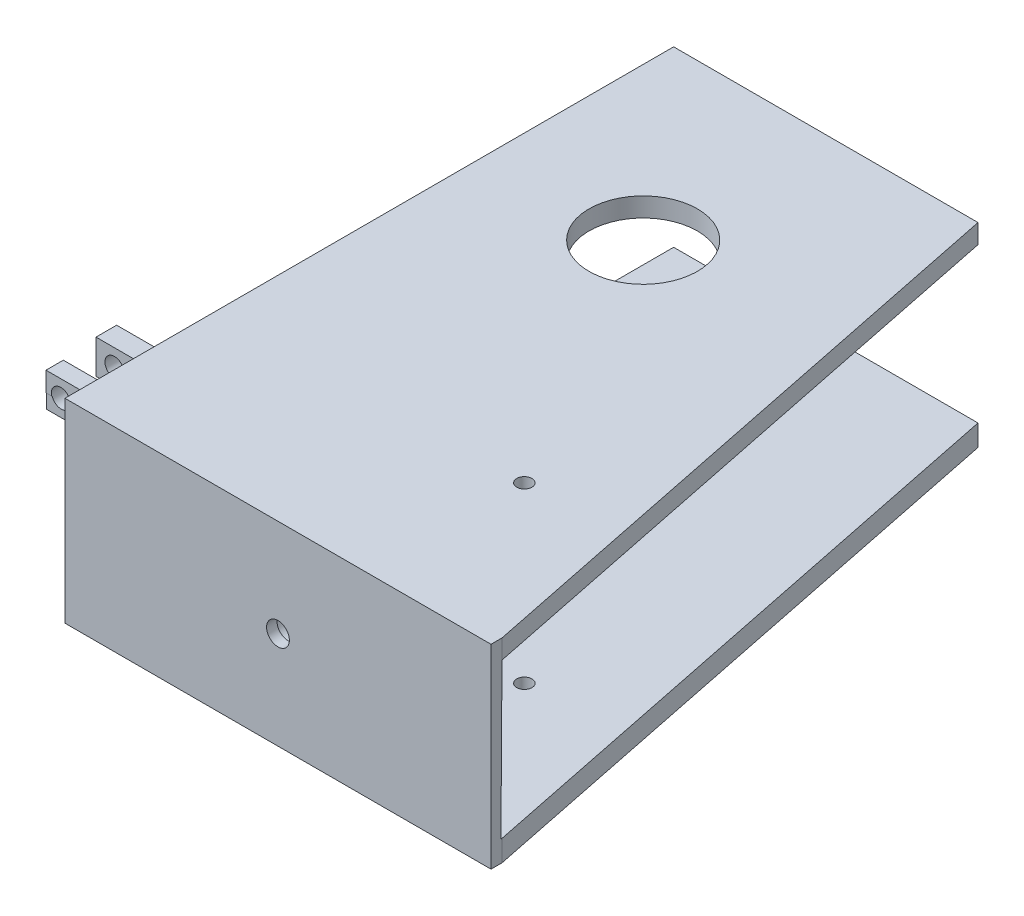
from build123d import *

# Parameters (mm, degrees)
SALIENTE_EXTRUIR1_DEPTH       = 4.572
CROQUIS2_W                    = 4.572
CROQUIS2_H                    = 76.2
SALIENTE_EXTRUIR2_DEPTH       = 177.8
SALIENTE_EXTRUIR3_DEPTH       = 5.08
SALIENTE_EXTRUIR3_DEPTH_BACK  = 76.2
CORTAR_EXTRUIR5_DEPTH         = 208.534
CROQUIS5_R                    = 12.7
CORTAR_EXTRUIR6_DEPTH         = 50.038
CORTAR_EXTRUIR6_DEPTH_BACK    = 148.336
CROQUIS6_R                    = 22.606
CORTAR_EXTRUIR12_DEPTH        = 33.274
CORTAR_EXTRUIR12_DEPTH_BACK   = 97.282
CROQUIS7_R                    = 7.975525782
CORTAR_EXTRUIR13_DEPTH        = 66.04
CORTAR_EXTRUIR13_DEPTH_BACK   = 177.8
CROQUIS8_R                    = 8.001
CROQUIS8_R_2                  = 7.975525782
SALIENTE_EXTRUIR8_DEPTH       = 19.304
SALIENTE_EXTRUIR8_DEPTH_BACK  = 18.034
CROQUIS9_R                    = 8.001
SALIENTE_EXTRUIR9_DEPTH       = 15.494
SALIENTE_EXTRUIR9_DEPTH_BACK  = 19.558
CROQUIS10_W                   = 16.002
CROQUIS10_H                   = 15.494
CORTAR_EXTRUIR14_DEPTH        = 261.874
CORTAR_EXTRUIR15_DEPTH        = 422.402
CROQUIS12_R                   = 8.001
SALIENTE_EXTRUIR10_DEPTH      = 118.618
CROQUIS13_W                   = 16.002
CROQUIS13_H                   = 64.433284084
CORTAR_EXTRUIR16_DEPTH        = 300.99
CORTAR_EXTRUIR17_DEPTH        = 262.89
CROQUIS15_R                   = 3.175
CORTAR_EXTRUIR18_DEPTH        = 120.142
CORTAR_EXTRUIR18_DEPTH_BACK   = 292.1
CROQUIS16_R                   = 4.7625
CORTAR_EXTRUIR20_DEPTH        = 446.532
CROQUIS20_R                   = 9.023236634
CROQUIS20_R_2                 = 5.413941981
SALIENTE_EXTRUIR12_DEPTH      = 206.502
SALIENTE_EXTRUIR12_DEPTH_BACK = 2.54
CROQUIS22_W                   = 184.818676859
CROQUIS22_H                   = 18.046473268
CORTAR_EXTRUIR21_DEPTH        = 252.984
CROQUIS23_W                   = 10.680092276
CROQUIS23_H                   = 18.046473268
CORTAR_EXTRUIR22_DEPTH        = 336.55
CROQUIS24_W                   = 7.23294038
CROQUIS24_H                   = 8.186318229
SALIENTE_EXTRUIR13_DEPTH      = 23.876
SALIENTE_EXTRUIR13_DEPTH_BACK = 22.098
CROQUIS25_W                   = 45.974
CROQUIS25_H                   = 6.021939504
SALIENTE_EXTRUIR14_DEPTH      = 193.548
SALIENTE_EXTRUIR14_DEPTH_BACK = 5.08
CROQUIS26_W                   = 191.576169951
CROQUIS26_H                   = 6.021939504
CORTAR_EXTRUIR23_DEPTH        = 184.658
CORTAR_EXTRUIR23_DEPTH_BACK   = 81.534
CROQUIS27_W                   = 8.610643309
CROQUIS27_H                   = 14.208257733
SALIENTE_EXTRUIR15_DEPTH      = 22.86
SALIENTE_EXTRUIR15_DEPTH_BACK = 23.622
CROQUIS28_R                   = 3.97256
CORTAR_EXTRUIR24_DEPTH        = 207.01


with BuildPart() as part:
    # Croquis1 → Saliente-Extruir1 (new body)
    with BuildSketch(Plane(origin=(0, 0, 0), x_dir=(1, 0, 0), z_dir=(0, 1, 0))):
        Polygon((0, 46.07031702), (0, -207.92968298), (177.8, -207.92968298), (127, 46.07031702), align=None)
    extrude(amount=SALIENTE_EXTRUIR1_DEPTH)

    # Croquis2 → Saliente-Extruir2 (add)
    with BuildSketch(Plane(origin=(0, 0, 0), x_dir=(0, 0, -1), z_dir=(1, 0, 0))):
        with Locations((-205.64368298, -33.528)):
            Rectangle(CROQUIS2_W, CROQUIS2_H)
    extrude(amount=SALIENTE_EXTRUIR2_DEPTH)

    # Croquis3 → Saliente-Extruir3 (add, two sides)
    with BuildSketch(Plane(origin=(0, 0, 0), x_dir=(1, 0, 0), z_dir=(0, 1, 0))) as saliente_extruir3_sk:
        Polygon((0, -207.92968298), (0, 46.07031702), (127, 46.07031702), (177.8, -203.35768298), (177.8, -207.92968298), align=None)
    extrude(amount=SALIENTE_EXTRUIR3_DEPTH)
    extrude(saliente_extruir3_sk.sketch, amount=-SALIENTE_EXTRUIR3_DEPTH_BACK)

    # Croquis4 → Cortar-Extruir5 (cut)
    with BuildSketch(Plane(origin=(0, 0, 0), x_dir=(0, 0, -1), z_dir=(1, 0, 0))):
        Polygon((46.07031702, -2.919454773), (46.07031702, -67.352738857), (-203.792527081, -67.352738857), (-203.35768298, -2.919454773), align=None)
    extrude(amount=CORTAR_EXTRUIR5_DEPTH, mode=Mode.SUBTRACT)

    # Croquis5 → Cortar-Extruir6 (cut, two sides)
    with BuildSketch(Plane(origin=(0, 0, 0), x_dir=(1, 0, 0), z_dir=(0, 1, 0))) as cortar_extruir6_sk:
        with Locations((63.5, -30.12968298)):
            Circle(CROQUIS5_R)
    extrude(amount=CORTAR_EXTRUIR6_DEPTH, mode=Mode.SUBTRACT)
    extrude(cortar_extruir6_sk.sketch, amount=-CORTAR_EXTRUIR6_DEPTH_BACK, mode=Mode.SUBTRACT)

    # Croquis6 → Cortar-Extruir12 (cut, two sides)
    with BuildSketch(Plane(origin=(0, 0, 0), x_dir=(1, 0, 0), z_dir=(0, 1, 0))) as cortar_extruir12_sk:
        with Locations((63.5, -30.12968298)):
            Circle(CROQUIS6_R)
    extrude(amount=CORTAR_EXTRUIR12_DEPTH, mode=Mode.SUBTRACT)
    extrude(cortar_extruir12_sk.sketch, amount=-CORTAR_EXTRUIR12_DEPTH_BACK, mode=Mode.SUBTRACT)

    # Croquis7 → Cortar-Extruir13 (cut, two sides)
    with BuildSketch(Plane(origin=(0, 0, 0), x_dir=(1, 0, 0), z_dir=(0, 1, 0))) as cortar_extruir13_sk:
        with Locations((122.352899809, -133.656770096)):
            Circle(CROQUIS7_R)
    extrude(amount=CORTAR_EXTRUIR13_DEPTH, mode=Mode.SUBTRACT)
    extrude(cortar_extruir13_sk.sketch, amount=-CORTAR_EXTRUIR13_DEPTH_BACK, mode=Mode.SUBTRACT)

    # Croquis8 → Saliente-Extruir8 (add, two sides)
    with BuildSketch(Plane.XZ.offset(76.2)) as saliente_extruir8_sk:
        with Locations((122.352899809, 133.656770096)):
            Circle(CROQUIS8_R)
        with Locations((122.352899809, 133.656770096)):
            Circle(CROQUIS8_R_2, mode=Mode.SUBTRACT)
    extrude(amount=SALIENTE_EXTRUIR8_DEPTH)
    extrude(saliente_extruir8_sk.sketch, amount=-SALIENTE_EXTRUIR8_DEPTH_BACK)

    # Croquis9 → Saliente-Extruir9 (add, two sides)
    with BuildSketch(Plane(origin=(0, 5.08, 0), x_dir=(1, 0, 0), z_dir=(0, 1, 0))) as saliente_extruir9_sk:
        with Locations((122.352899809, -133.656770096)):
            Circle(CROQUIS9_R)
    extrude(amount=SALIENTE_EXTRUIR9_DEPTH)
    extrude(saliente_extruir9_sk.sketch, amount=-SALIENTE_EXTRUIR9_DEPTH_BACK)

    # Croquis10 → Cortar-Extruir14 (cut)
    with BuildSketch(Plane(origin=(0, 0, 0), x_dir=(0, 0, -1), z_dir=(1, 0, 0))):
        with Locations((-133.656770096, 12.827)):
            Rectangle(CROQUIS10_W, CROQUIS10_H)
    extrude(amount=CORTAR_EXTRUIR14_DEPTH, mode=Mode.SUBTRACT)

    # Croquis11 → Cortar-Extruir15 (cut)
    with BuildSketch(Plane(origin=(0, 0, 0), x_dir=(0, 0, -1), z_dir=(1, 0, 0))):
        Polygon((-142.139346511, -2.919454773), (-142.052853493, -14.491925991), (-125.655770096, -14.478), (-125.655770096, -2.919454773), align=None)
        Polygon((-141.657770096, -67.352738857), (-125.655770096, -67.352738857), (-125.655770096, -57.997233167), (-141.727693443, -57.997233167), align=None)
    extrude(amount=CORTAR_EXTRUIR15_DEPTH, mode=Mode.SUBTRACT)

    # Croquis12 → Saliente-Extruir10 (add)
    with BuildSketch(Plane(origin=(0, 0, 0), x_dir=(1, 0, 0), z_dir=(0, 1, 0))):
        with Locations((122.352899809, -133.656770096)):
            Circle(CROQUIS12_R)
    extrude(amount=-SALIENTE_EXTRUIR10_DEPTH)

    # Croquis13 → Cortar-Extruir16 (cut)
    with BuildSketch(Plane(origin=(0, 0, 0), x_dir=(0, 0, -1), z_dir=(1, 0, 0))):
        with Locations((-133.656770096, -35.136096815)):
            Rectangle(CROQUIS13_W, CROQUIS13_H)
    extrude(amount=CORTAR_EXTRUIR16_DEPTH, mode=Mode.SUBTRACT)

    # Croquis14 → Cortar-Extruir17 (cut)
    with BuildSketch(Plane(origin=(0, 0, 0), x_dir=(0, 0, -1), z_dir=(1, 0, 0))):
        Polygon((-141.823129416, -76.2), (-141.657770096, -118.618), (-125.655770096, -118.618), (-125.655770096, -76.2), align=None)
    extrude(amount=CORTAR_EXTRUIR17_DEPTH, mode=Mode.SUBTRACT)

    # Croquis15 → Cortar-Extruir18 (cut, two sides)
    with BuildSketch(Plane(origin=(0, 0, 0), x_dir=(1, 0, 0), z_dir=(0, 1, 0))) as cortar_extruir18_sk:
        with Locations((126.414802626, -142.640423395)):
            Circle(CROQUIS15_R)
    extrude(amount=CORTAR_EXTRUIR18_DEPTH, mode=Mode.SUBTRACT)
    extrude(cortar_extruir18_sk.sketch, amount=-CORTAR_EXTRUIR18_DEPTH_BACK, mode=Mode.SUBTRACT)

    # Croquis16 → Cortar-Extruir20 (cut)
    with BuildSketch(Plane.XY):
        with Locations((88.9, -35.56)):
            Circle(CROQUIS16_R)
    extrude(amount=CORTAR_EXTRUIR20_DEPTH, mode=Mode.SUBTRACT)

    # Croquis20 → Saliente-Extruir12 (add, two sides)
    with BuildSketch(Plane.XY) as saliente_extruir12_sk:
        with Locations((88.9, -35.56)):
            Circle(CROQUIS20_R)
        with Locations((88.9, -35.56)):
            Circle(CROQUIS20_R_2, mode=Mode.SUBTRACT)
    extrude(amount=SALIENTE_EXTRUIR12_DEPTH)
    extrude(saliente_extruir12_sk.sketch, amount=-SALIENTE_EXTRUIR12_DEPTH_BACK)

    # Croquis22 → Cortar-Extruir21 (cut)
    with BuildSketch(Plane(origin=(0, 0, 0), x_dir=(0, 0, -1), z_dir=(1, 0, 0))):
        with Locations((-89.86933843, -35.56)):
            Rectangle(CROQUIS22_W, CROQUIS22_H)
    extrude(amount=CORTAR_EXTRUIR21_DEPTH, mode=Mode.SUBTRACT)

    # Croquis23 → Cortar-Extruir22 (cut)
    with BuildSketch(Plane(origin=(0, 0, 0), x_dir=(0, 0, -1), z_dir=(1, 0, 0))):
        with Locations((-187.618722997, -35.56)):
            Rectangle(CROQUIS23_W, CROQUIS23_H)
    extrude(amount=CORTAR_EXTRUIR22_DEPTH, mode=Mode.SUBTRACT)

    # Croquis24 → Saliente-Extruir13 (add, two sides)
    with BuildSketch(Plane(origin=(0, 0, 0), x_dir=(0, 0, -1), z_dir=(1, 0, 0))) as saliente_extruir13_sk:
        with Locations((-190.112640141, -7.012613888)):
            Rectangle(CROQUIS24_W, CROQUIS24_H)
    extrude(amount=SALIENTE_EXTRUIR13_DEPTH)
    extrude(saliente_extruir13_sk.sketch, amount=-SALIENTE_EXTRUIR13_DEPTH_BACK)

    # Croquis25 → Saliente-Extruir14 (add, two sides)
    with BuildSketch(Plane.XY) as saliente_extruir14_sk:
        with Locations((0.889, -14.116742754)):
            Rectangle(CROQUIS25_W, CROQUIS25_H)
    extrude(amount=SALIENTE_EXTRUIR14_DEPTH)
    extrude(saliente_extruir14_sk.sketch, amount=-SALIENTE_EXTRUIR14_DEPTH_BACK)

    # Croquis26 → Cortar-Extruir23 (cut, two sides)
    with BuildSketch(Plane(origin=(0, 0, 0), x_dir=(0, 0, -1), z_dir=(1, 0, 0))) as cortar_extruir23_sk:
        with Locations((-90.708084976, -14.116742754)):
            Rectangle(CROQUIS26_W, CROQUIS26_H)
    extrude(amount=CORTAR_EXTRUIR23_DEPTH, mode=Mode.SUBTRACT)
    extrude(cortar_extruir23_sk.sketch, amount=-CORTAR_EXTRUIR23_DEPTH_BACK, mode=Mode.SUBTRACT)

    # Croquis27 → Saliente-Extruir15 (add, two sides)
    with BuildSketch(Plane(origin=(0, 0, 0), x_dir=(0, 0, -1), z_dir=(1, 0, 0))) as saliente_extruir15_sk:
        with Locations((-167.036116073, -10.023583639)):
            Rectangle(CROQUIS27_W, CROQUIS27_H)
    extrude(amount=SALIENTE_EXTRUIR15_DEPTH)
    extrude(saliente_extruir15_sk.sketch, amount=-SALIENTE_EXTRUIR15_DEPTH_BACK)

    # Croquis28 → Cortar-Extruir24 (cut)
    with BuildSketch(Plane.XY):
        with Locations((-15.911630765, -10.02358364)):
            Circle(CROQUIS28_R)
    extrude(amount=CORTAR_EXTRUIR24_DEPTH, mode=Mode.SUBTRACT)


solid = part.part
